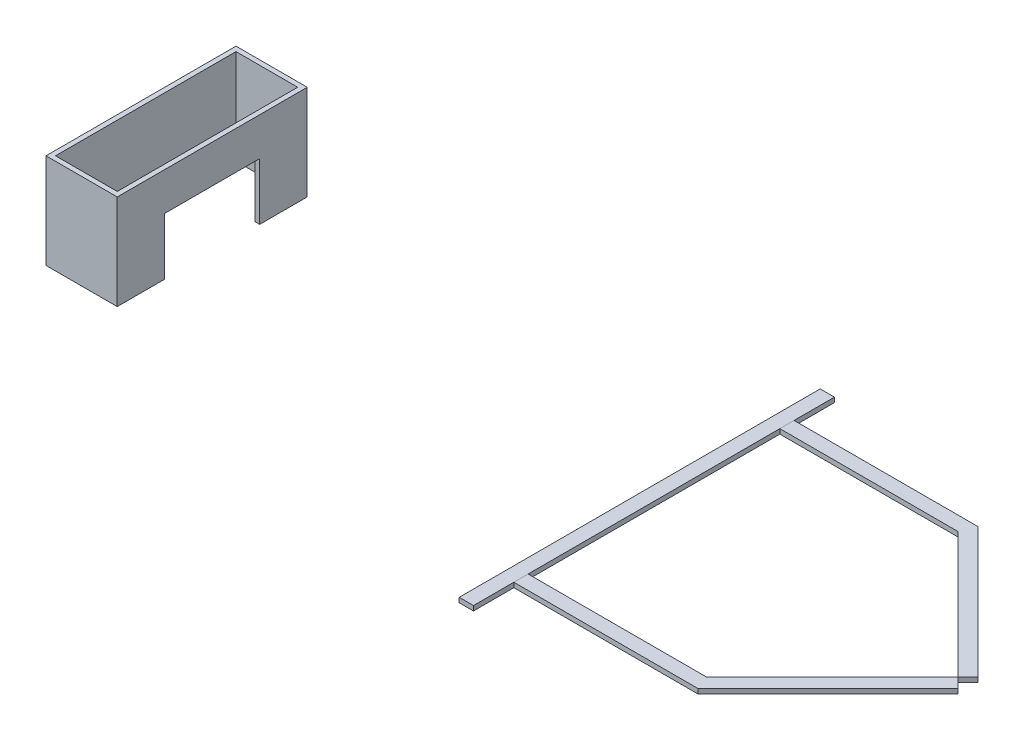
from build123d import *

# Parameters (mm, degrees)
BOSS_EXTRUDE2_DEPTH   = 10
BOSS_EXTRUDE2_2_DEPTH = 10
SKETCH2_W             = 30
SKETCH2_H             = 760
BOSS_EXTRUDE9_DEPTH   = 10
SKETCH3_W             = 150
SKETCH3_H             = 400
BOSS_EXTRUDE10_DEPTH  = 200
SKETCH4_W             = 130
SKETCH4_H             = 380
CUT_EXTRUDE2_DEPTH    = 200
SKETCH5_W             = 200
SKETCH5_H             = 120
CUT_EXTRUDE3_DEPTH    = 10


with BuildPart() as part:
    # Sketch1 → Boss-Extrude2 (new body)
    with BuildSketch(Plane(origin=(0, 0, 0), x_dir=(1, 0, 0), z_dir=(0, 1, 0))):
        Polygon((-292.942154032, -394.648768766), (81.824439968, -394.648768766), (346.824439968, -129.648768766), (368.037643404, -150.861972202), (94.250846839, -424.648768766), (-292.942154032, -424.648768766), align=None)
    extrude(amount=BOSS_EXTRUDE2_DEPTH)


with BuildPart() as body_2:
    # Sketch1 → Boss-Extrude2 2 (new body)
    with BuildSketch(Plane(origin=(0, 0, 0), x_dir=(1, 0, 0), z_dir=(0, 1, 0))):
        Polygon((346.824439968, -129.648768766), (368.037643404, -108.435565331), (94.250846839, 165.351231234), (-292.942154032, 165.351231234), (-292.942154032, 135.351231234), (81.824439968, 135.351231234), align=None)
    extrude(amount=BOSS_EXTRUDE2_2_DEPTH)


with BuildPart() as body_3:
    # Sketch2 → Boss-Extrude9 (new body)
    with BuildSketch(Plane(origin=(0, 0, 0), x_dir=(1, 0, 0), z_dir=(0, 1, 0))):
        with Locations((-307.952154032, -129.648768766)):
            Rectangle(SKETCH2_W, SKETCH2_H)
    extrude(amount=BOSS_EXTRUDE9_DEPTH)


with BuildPart() as body_4:
    # Sketch3 → Boss-Extrude10 (new body)
    with BuildSketch(Plane(origin=(0, 0, 0), x_dir=(1, 0, 0), z_dir=(0, 1, 0))):
        with Locations((-1297.952154032, -129.648768766)):
            Rectangle(SKETCH3_W, SKETCH3_H)
    extrude(amount=BOSS_EXTRUDE10_DEPTH)

    # Sketch4 → Cut-Extrude2 (cut)
    with BuildSketch(Plane(origin=(0, 0, 0), x_dir=(1, 0, 0), z_dir=(0, 1, 0))):
        with Locations((-1297.952154032, -129.648768766)):
            Rectangle(SKETCH4_W, SKETCH4_H)
    extrude(amount=CUT_EXTRUDE2_DEPTH, mode=Mode.SUBTRACT)

    # Sketch5 → Cut-Extrude3 (cut)
    with BuildSketch(Plane(origin=(-1222.952154032, 0, 0), x_dir=(0, 0, -1), z_dir=(1, 0, 0))):
        with Locations((-129.648768766, 60)):
            Rectangle(SKETCH5_W, SKETCH5_H)
    extrude(amount=-CUT_EXTRUDE3_DEPTH, mode=Mode.SUBTRACT)


solid = Compound([part.part, body_2.part, body_3.part, body_4.part])
